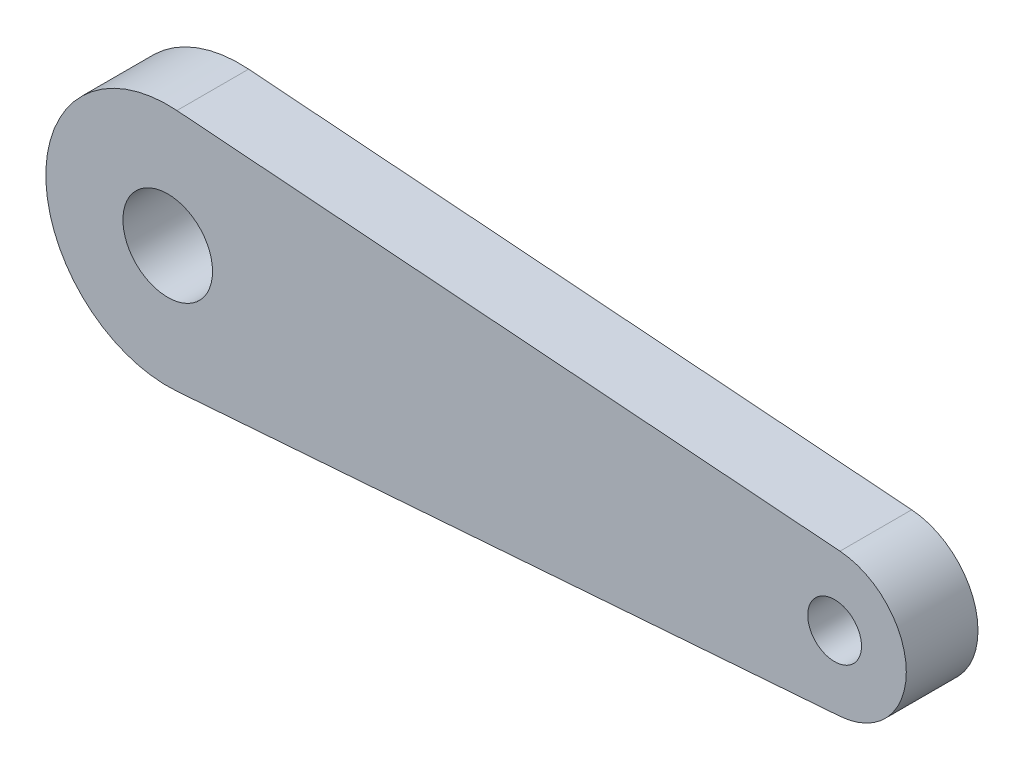
from build123d import *

# Parameters (mm, degrees)
SKETCH1_R   = 0.75
SKETCH1_R_2 = 1.25
MAIN_DEPTH  = 2


with BuildPart() as part:
    # Sketch1 → Main (new body)
    with BuildSketch(Plane.XY):
        with BuildLine():
            Line((0.255913978, 3.390355149), (18.750537634, 1.994326558))
            ThreePointArc((18.750537634, 1.994326558), (20.6, 0), (18.750537634, -1.994326558))
            Line((18.750537634, -1.994326558), (0.255913978, -3.390355149))
            ThreePointArc((0.255913978, -3.390355149), (-3.4, 0), (0.255913978, 3.390355149))
        make_face()
        with Locations((18.6, 0)):
            Circle(SKETCH1_R, mode=Mode.SUBTRACT)
        Circle(SKETCH1_R_2, mode=Mode.SUBTRACT)
    extrude(amount=MAIN_DEPTH)


solid = part.part
